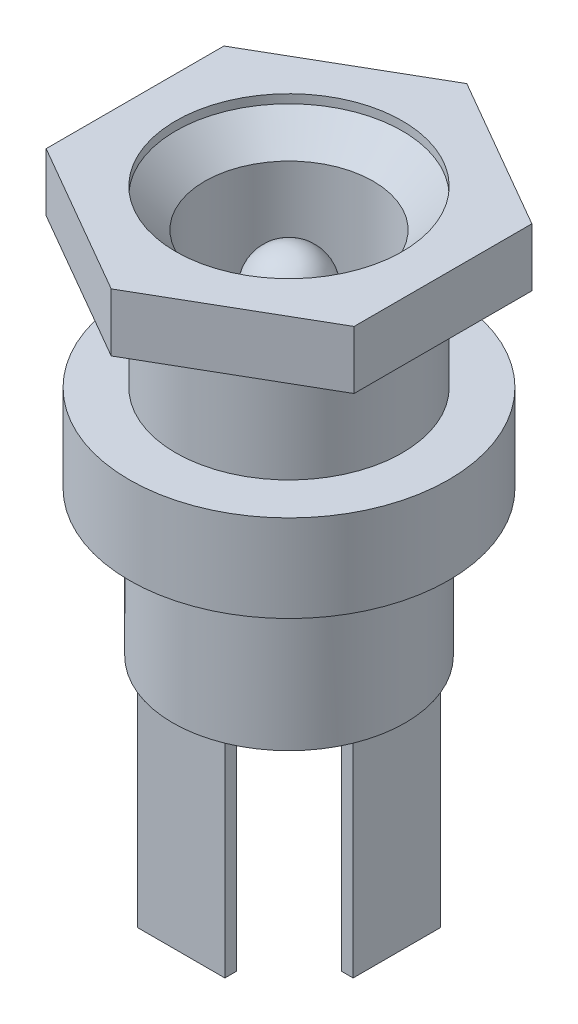
from build123d import *

# Parameters (mm, degrees)
BOSS_EXTRUDE1_START = 4
SKETCH2_R           = 3.9
BOSS_EXTRUDE1_DEPTH = 2
SKETCH3_W           = 3
SKETCH3_H           = 0.4
BOSS_EXTRUDE2_DEPTH = 7
CIRPATTERN1_COUNT   = 3
CIRPATTERN1_ANGLE   = 180


with BuildPart() as part:
    # Sketch1 → Revolve1 (revolve)
    with BuildSketch(Plane(origin=(0, 0, 0), x_dir=(0, 0, -1), z_dir=(1, 0, 0))):
        with BuildLine():
            Line((-3.9, 13.7), (-3.9, 8))
            Line((-3.9, 8), (-5.5, 8))
            Line((-5.5, 8), (-5.5, 5))
            Line((-5.5, 5), (-4, 5))
            Line((-4, 5), (-4, 0))
            Line((-4, 0), (0, 0))
            Line((0, 0), (0, 12.2))
            ThreePointArc((0, 12.2), (-0.883883476, 11.833883476), (-1.25, 10.95))
            Line((-1.25, 10.95), (-1.25, 6.7))
            Line((-1.25, 6.7), (-2.9, 6.7))
            Line((-2.9, 6.7), (-2.9, 12.7))
            Line((-2.9, 12.7), (-3.9, 13.7))
        make_face()
    revolve(axis=Axis((0, 12.2, 0), (0, -1, 0)))

    # Sketch2 → Boss-Extrude1 (add)
    with BuildSketch(Plane(origin=(0, 8, 0), x_dir=(1, 0, 0), z_dir=(0, 1, 0)).offset(BOSS_EXTRUDE1_START)):
        Polygon((5.3, 3.059956427), (0, 6.119912853), (-5.3, 3.059956427), (-5.3, -3.059956427), (0, -6.119912853), (5.3, -3.059956427), align=None)
        Circle(SKETCH2_R, mode=Mode.SUBTRACT)
    extrude(amount=BOSS_EXTRUDE1_DEPTH)

    # Sketch3 → Boss-Extrude2 (add)
    with BuildSketch(Plane.XZ):
        with Locations((0, 3.508099244)):
            Rectangle(SKETCH3_W, SKETCH3_H)
    boss_extrude2 = extrude(amount=BOSS_EXTRUDE2_DEPTH)

    # CirPattern1: Boss-Extrude2 ×3 about axis
    cirpattern1_axis = Axis((0, 0, 0), (0, 1, 0))
    for i in range(1, CIRPATTERN1_COUNT):
        add(boss_extrude2.rotate(cirpattern1_axis, i * CIRPATTERN1_ANGLE / (CIRPATTERN1_COUNT - 1)))


solid = part.part
